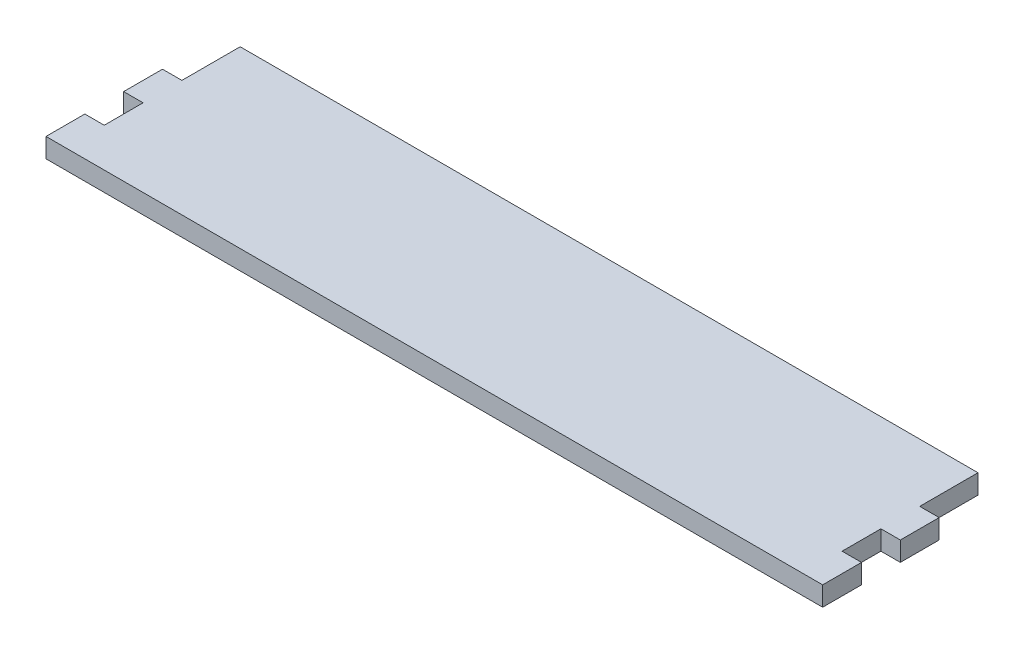
from build123d import *

# Parameters (mm, degrees)
SKETCH_1_W          = 200
SKETCH_1_H          = 45
EXTRUDE_1_DEPTH     = 5
SKETCH_2_W          = 5
SKETCH_2_H          = 15
SKETCH_2_H_2        = 10
CUT_EXTRUDE_1_DEPTH = 6


with BuildPart() as part:
    # 草图1 → 凸台-拉伸1 (new body)
    with BuildSketch(Plane(origin=(0, 0, 0), x_dir=(1, 0, 0), z_dir=(0, 1, 0))):
        Rectangle(SKETCH_1_W, SKETCH_1_H)
    extrude(amount=EXTRUDE_1_DEPTH)

    # 草图2 → 切除-拉伸1 (cut, through all)
    with BuildSketch(Plane(origin=(0, 5, 0), x_dir=(1, 0, 0), z_dir=(0, 1, 0))):
        with Locations((-97.5, 15)):
            Rectangle(SKETCH_2_W, SKETCH_2_H)
        with Locations((-97.5, -7.5)):
            Rectangle(SKETCH_2_W, SKETCH_2_H_2)
        with Locations((97.5, 15)):
            Rectangle(SKETCH_2_W, SKETCH_2_H)
        with Locations((97.5, -7.5)):
            Rectangle(SKETCH_2_W, SKETCH_2_H_2)
    extrude(amount=-CUT_EXTRUDE_1_DEPTH, mode=Mode.SUBTRACT)


solid = part.part
